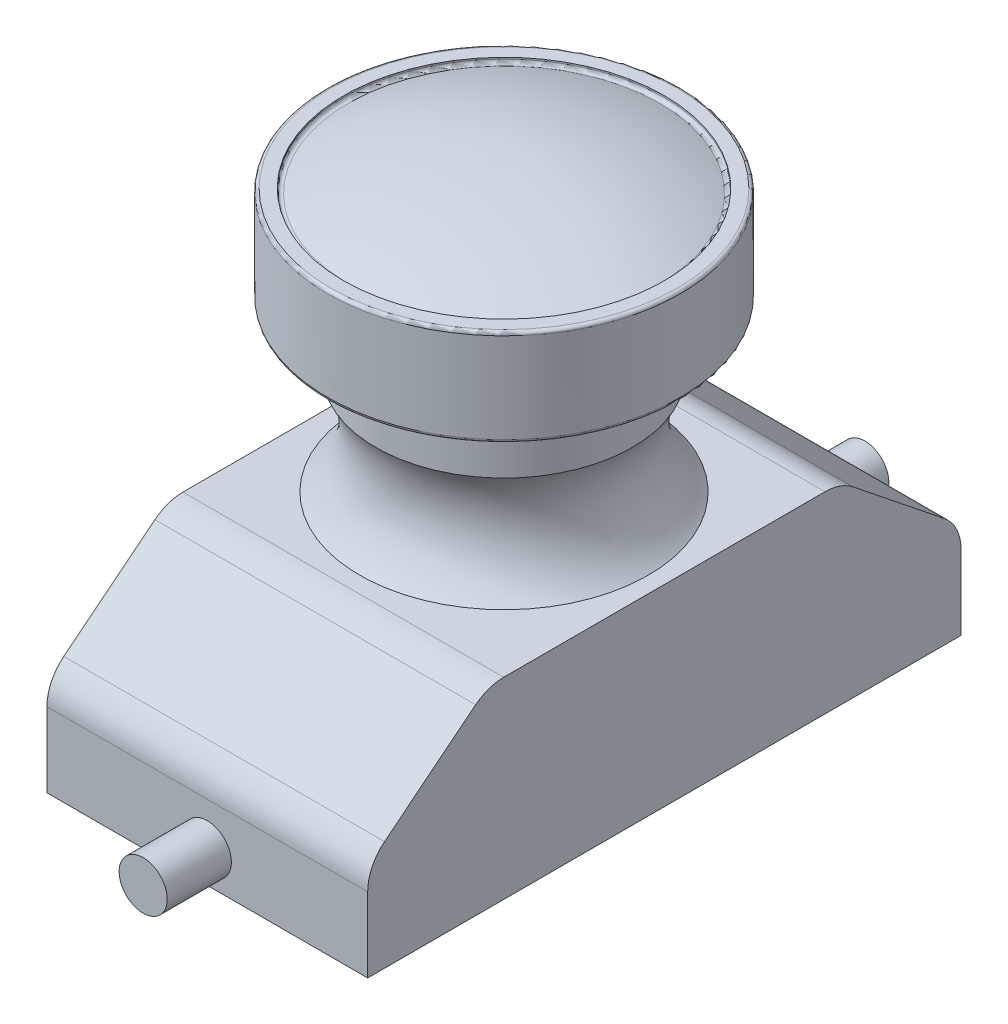
from build123d import *

# Parameters (mm, degrees)
BOSS_EXTRUDE1_DEPTH = 5
FILLET1_R           = 0.1
FILLET2_R           = 0.1
FILLET3_R           = 1.4
SKETCH4_R           = 0.75
BOSS_EXTRUDE2_DEPTH = 2


with BuildPart() as part:
    # Sketch1 → Boss-Extrude1 (new body, symmetric)
    with BuildSketch(Plane(origin=(0, 0, 0), x_dir=(0, 0, -1), z_dir=(1, 0, 0))):
        Polygon((-9.25, 0), (9.25, 0), (9.25, 3), (5.5, 6), (-5.5, 6), (-9.25, 3), align=None)
    extrude(amount=BOSS_EXTRUDE1_DEPTH, both=True)

    # Sketch2 → Revolve1 (revolve)
    with BuildSketch(Plane(origin=(0, 0, 0), x_dir=(0, 0, -1), z_dir=(1, 0, 0))):
        with BuildLine():
            Line((0, 6), (0, 14))
            Line((0, 14), (5, 14))
            Line((5, 14), (5, 14.2))
            Line((5, 14.2), (5.5, 14.2))
            Line((5.5, 14.2), (5.5, 11.2))
            Line((5.5, 11.2), (4, 11.2))
            Line((4, 11.2), (4, 9.2))
            ThreePointArc((4, 9.2), (3.661737334, 7.508083958), (4.5, 6))
            Line((4.5, 6), (0, 6))
        make_face()
    revolve(axis=Axis((0, 6, 0), (0, 1, 0)))

    # Sketch3 → Revolve2 (revolve)
    with BuildSketch(Plane(origin=(0, 0, 0), x_dir=(0, 0, -1), z_dir=(1, 0, 0))):
        with BuildLine():
            Line((0, 14.2), (0, 15))
            ThreePointArc((0, 15), (-2.553728094, 14.768640471), (-5, 14))
            Line((-5, 14), (0, 14))
            Line((0, 14), (0, 14.2))
        make_face()
    revolve(axis=Axis((0, 14.2, 0), (0, 1, 0)))

    # Fillet1
    fillet1_edges = [part.edges().sort_by_distance(p)[0] for p in [
        (0, 11.2, 5.5),
        (0, 14.2, 5.5),
    ]]
    fillet(fillet1_edges, radius=FILLET1_R)

    # Fillet2
    fillet2_edges = [part.edges().sort_by_distance(p)[0] for p in [
        (5, 14, 0),
    ]]
    fillet(fillet2_edges, radius=FILLET2_R)

    # Fillet3
    fillet3_edges = [part.edges().sort_by_distance(p)[0] for p in [
        (0, 3, 9.25),
        (0, 6, 5.5),
        (0, 6, -5.5),
        (0, 3, -9.25),
    ]]
    fillet(fillet3_edges, radius=FILLET3_R)

    # Sketch4 → Boss-Extrude2 (add)
    with BuildSketch(Plane(origin=(0, 0, -9.25), x_dir=(-1, 0, 0), z_dir=(0, 0, -1))):
        with Locations((0, 1)):
            Circle(SKETCH4_R)
    boss_extrude2 = extrude(amount=BOSS_EXTRUDE2_DEPTH)

    # Mirror1: Boss-Extrude2 across plane
    add(boss_extrude2.mirror(Plane.XY))


solid = part.part
